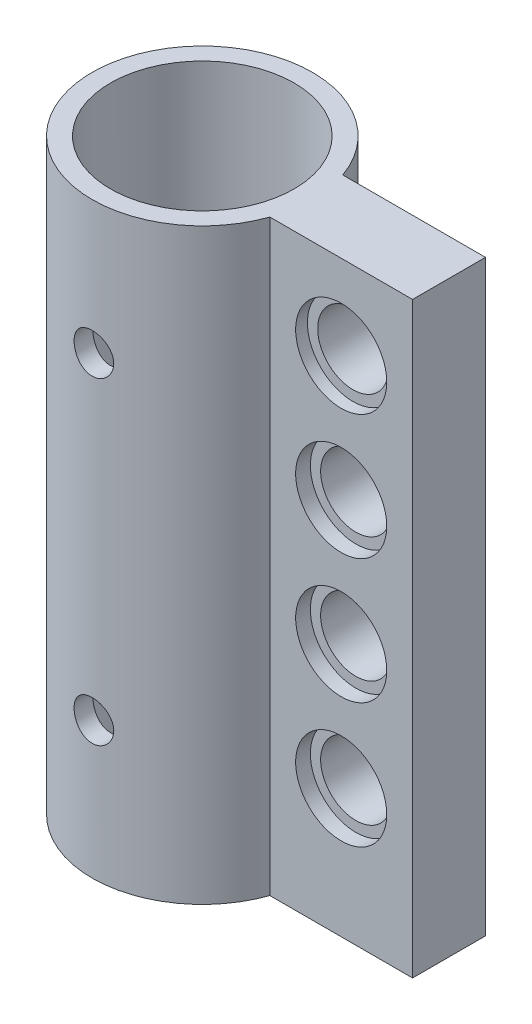
from build123d import *

# Parameters (mm, degrees)
BOSS_EXTRUDE1_DEPTH     = 20
SKETCH2_R               = 2.4
CUT_EXTRUDE2_DEPTH      = 28.957878519
SKETCH3_R               = 3.1
CUT_EXTRUDE3_DEPTH      = 0.8
CUT_EXTRUDE4_REACH      = 34.348
CUT_EXTRUDE4_END_RADIUS = 6.25
SKETCH4_R               = 1.35
SKETCH5_R               = 1.35
CUT_EXTRUDE5_DEPTH      = 5
SKETCH6_R               = 2.4
CUT_EXTRUDE6_DEPTH      = 5
SKETCH7_R               = 3.1
CUT_EXTRUDE7_DEPTH      = 1


with BuildPart() as part:
    # Sketch1 → Boss-Extrude1 (new body)
    with BuildSketch(Plane(origin=(0, 0, 0), x_dir=(1, 0, 0), z_dir=(0, 1, 0))):
        with BuildLine():
            Line((7.077642728, 2.481324931), (16.7933357, 2.481324931))
            Line((16.7933357, 2.481324931), (16.7933357, 0.453397708))
            Line((16.7933357, 0.453397708), (16.7933357, -0.453397708))
            Line((16.7933357, -0.453397708), (16.7933357, -2.481324931))
            Line((16.7933357, -2.481324931), (7.077642728, -2.481324931))
            ThreePointArc((7.077642728, -2.481324931), (-7.5, 0), (7.077642728, 2.481324931))
        make_face()
        with BuildLine():
            ThreePointArc((6.109239102, 1.318975964), (-6.25, 0), (6.109239102, -1.318975964))
            ThreePointArc((6.109239102, -1.318975964), (6.25, 0), (6.109239102, 1.318975964))
        make_face(mode=Mode.SUBTRACT)
    boss_extrude1 = extrude(amount=BOSS_EXTRUDE1_DEPTH)

    # Sketch2 → Cut-Extrude2 (cut, through all)
    with BuildSketch(Plane.XY.offset(2.481324931)):
        with Locations((11.935489214, 14.25)):
            Circle(SKETCH2_R)
        with Locations((11.935489214, 5.75)):
            Circle(SKETCH2_R)
    extrude(amount=-CUT_EXTRUDE2_DEPTH, mode=Mode.SUBTRACT)

    # Sketch3 → Cut-Extrude3 (cut)
    with BuildSketch(Plane.XY.offset(2.481324931)):
        with Locations((11.935489214, 14.25)):
            Circle(SKETCH3_R)
        with Locations((11.935489214, 5.75)):
            Circle(SKETCH3_R)
    extrude(amount=-CUT_EXTRUDE3_DEPTH, mode=Mode.SUBTRACT)

    # Cut-Extrude4: up to this cylinder (the profile starts outside it)
    cut_extrude4_end = Plane(origin=(0, 10.443469, 0), z_dir=(0, -1, 0)) * Cylinder(CUT_EXTRUDE4_END_RADIUS, 82.196, mode=Mode.PRIVATE)
    # Sketch4 → Cut-Extrude4 (cut, up to the surface)
    with BuildSketch(Plane.ZY.offset(7.5), mode=Mode.PRIVATE) as cut_extrude4_sk1:
        with Locations((0, 10.443469374)):
            Circle(SKETCH4_R)
    cut_extrude4_tool1 = extrude(cut_extrude4_sk1.sketch, amount=-CUT_EXTRUDE4_REACH, mode=Mode.PRIVATE) - cut_extrude4_end
    cut_extrude4 = cut_extrude4_tool1.solids().sort_by_distance((-7.5, 10.443469, 0))[0]
    add(cut_extrude4, mode=Mode.SUBTRACT)

    # Mirror2: Boss-Extrude1, Cut-Extrude4 across plane
    add(boss_extrude1.mirror(Plane.ZX))
    add(cut_extrude4.mirror(Plane.ZX), mode=Mode.SUBTRACT)

    # Sketch5 → Cut-Extrude5 (cut)
    with BuildSketch(Plane.XY.offset(7.5)):
        with Locations((0, 10.938911234)):
            Circle(SKETCH5_R)
        with Locations((0, -10.702394235)):
            Circle(SKETCH5_R)
    extrude(amount=-CUT_EXTRUDE5_DEPTH, mode=Mode.SUBTRACT)

    # Sketch6 → Cut-Extrude6 (cut)
    with BuildSketch(Plane.XY.offset(2.481324931)):
        with Locations((11.935489214, -11.25)):
            Circle(SKETCH6_R)
        with Locations((11.935489214, -2.75)):
            Circle(SKETCH6_R)
    extrude(amount=-CUT_EXTRUDE6_DEPTH, mode=Mode.SUBTRACT)

    # Sketch7 → Cut-Extrude7 (cut)
    with BuildSketch(Plane.XY.offset(2.481324931)):
        with Locations((11.935489214, 5.75)):
            Circle(SKETCH7_R)
        with Locations((11.935489214, -2.75)):
            Circle(SKETCH7_R)
        with Locations((11.935489214, -11.25)):
            Circle(SKETCH7_R)
    extrude(amount=-CUT_EXTRUDE7_DEPTH, mode=Mode.SUBTRACT)


solid = part.part
